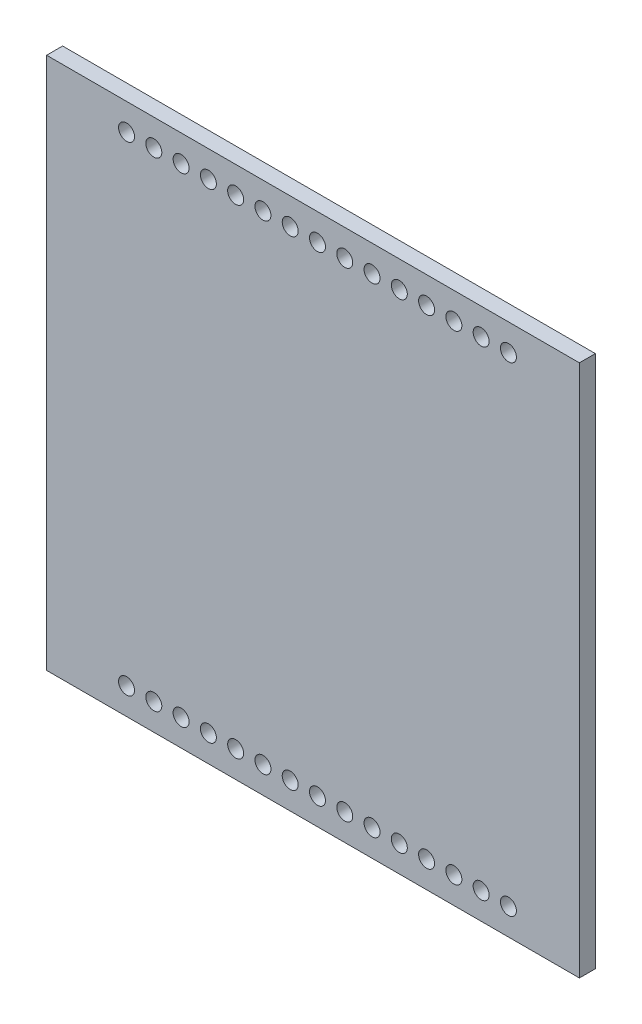
from build123d import *

# Parameters (mm, degrees)
SKETCH1_W           = 50
SKETCH1_H           = 50
BOSS_EXTRUDE1_DEPTH = 1.5
SKETCH2_R           = 0.75
CUT_EXTRUDE1_DEPTH  = 2.5


with BuildPart() as part:
    # Sketch1 → Boss-Extrude1 (new body)
    with BuildSketch(Plane.XY):
        Rectangle(SKETCH1_W, SKETCH1_H)
    extrude(amount=BOSS_EXTRUDE1_DEPTH)

    # Sketch2 → Cut-Extrude1 (cut, through all)
    with BuildSketch(Plane.XY.offset(1.5)):
        with Locations((-17.5, -22.5)):
            Circle(SKETCH2_R)
        with Locations((-14.94, -22.5)):
            Circle(SKETCH2_R)
        with Locations((-12.38, -22.5)):
            Circle(SKETCH2_R)
        with Locations((-9.82, -22.5)):
            Circle(SKETCH2_R)
        with Locations((-7.26, -22.5)):
            Circle(SKETCH2_R)
        with Locations((-4.7, -22.5)):
            Circle(SKETCH2_R)
        with Locations((-2.14, -22.5)):
            Circle(SKETCH2_R)
        with Locations((0.42, -22.5)):
            Circle(SKETCH2_R)
        with Locations((2.98, -22.5)):
            Circle(SKETCH2_R)
        with Locations((5.54, -22.5)):
            Circle(SKETCH2_R)
        with Locations((8.1, -22.5)):
            Circle(SKETCH2_R)
        with Locations((10.66, -22.5)):
            Circle(SKETCH2_R)
        with Locations((13.22, -22.5)):
            Circle(SKETCH2_R)
        with Locations((15.78, -22.5)):
            Circle(SKETCH2_R)
        with Locations((18.34, -22.5)):
            Circle(SKETCH2_R)
        with Locations((18.34, 22.5)):
            Circle(SKETCH2_R)
        with Locations((15.78, 22.5)):
            Circle(SKETCH2_R)
        with Locations((13.22, 22.5)):
            Circle(SKETCH2_R)
        with Locations((10.66, 22.5)):
            Circle(SKETCH2_R)
        with Locations((8.1, 22.5)):
            Circle(SKETCH2_R)
        with Locations((5.54, 22.5)):
            Circle(SKETCH2_R)
        with Locations((2.98, 22.5)):
            Circle(SKETCH2_R)
        with Locations((0.42, 22.5)):
            Circle(SKETCH2_R)
        with Locations((-2.14, 22.5)):
            Circle(SKETCH2_R)
        with Locations((-4.7, 22.5)):
            Circle(SKETCH2_R)
        with Locations((-7.26, 22.5)):
            Circle(SKETCH2_R)
        with Locations((-9.82, 22.5)):
            Circle(SKETCH2_R)
        with Locations((-12.38, 22.5)):
            Circle(SKETCH2_R)
        with Locations((-14.94, 22.5)):
            Circle(SKETCH2_R)
        with Locations((-17.5, 22.5)):
            Circle(SKETCH2_R)
    extrude(amount=-CUT_EXTRUDE1_DEPTH, mode=Mode.SUBTRACT)


solid = part.part
